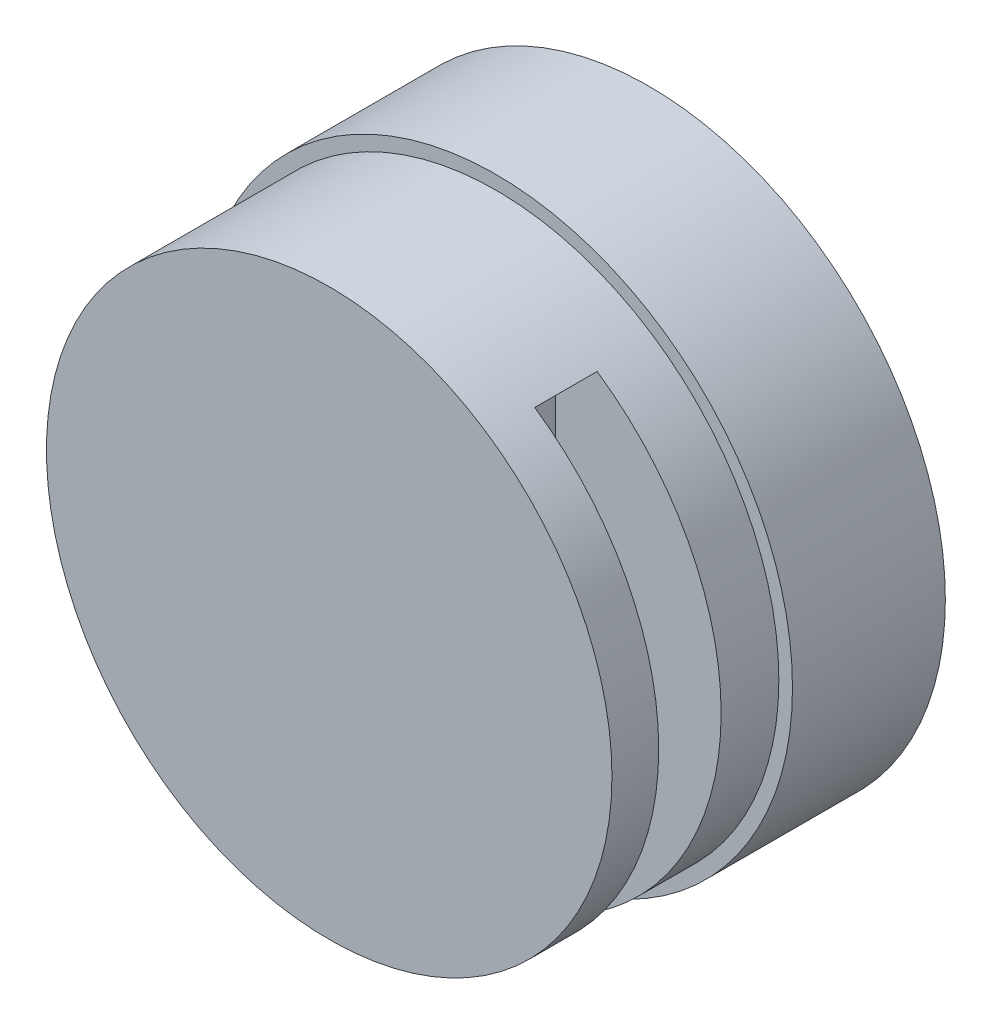
from build123d import *

# Parameters (mm, degrees)
SKETCH_1_R          = 38
EXTRUDE_1_DEPTH     = 19.6
SKETCH_2_R          = 36.25
EXTRUDE_2_DEPTH     = 21.4
SKETCH_3_R          = 1.5
CUT_EXTRUDE_1_DEPTH = 4
CUT_EXTRUDE_2_REACH = 55
CUT_EXTRUDE_START   = 15
SKETCH_5_W          = 8
SKETCH_5_H          = 60


with BuildPart() as part:
    # 草图1 → 凸台-拉伸1 (new body)
    with BuildSketch(Plane.XY):
        Circle(SKETCH_1_R)
    extrude(amount=EXTRUDE_1_DEPTH)

    # 草图2 → 凸台-拉伸2 (add)
    with BuildSketch(Plane.XY.offset(19.6)):
        Circle(SKETCH_2_R)
    extrude(amount=EXTRUDE_2_DEPTH)

    # 草图3 → 切除-拉伸1 (cut)
    with BuildSketch(Plane(origin=(0, 0, 0), x_dir=(-1, 0, 0), z_dir=(0, 0, -1))):
        with Locations((20.859650045, 20.859650045)):
            Circle(SKETCH_3_R)
        with Locations((20.859650045, -20.859650045)):
            Circle(SKETCH_3_R)
        with Locations((-20.859650045, -20.859650045)):
            Circle(SKETCH_3_R)
        with Locations((-20.859650045, 20.859650045)):
            Circle(SKETCH_3_R)
    extrude(amount=-CUT_EXTRUDE_1_DEPTH, mode=Mode.SUBTRACT)

    # 草图5 → 切除-拉伸2 (cut, up to next)
    with BuildSketch(Plane(origin=(0, 0, 0), x_dir=(0, 0, -1), z_dir=(1, 0, 0)).offset(CUT_EXTRUDE_START), mode=Mode.PRIVATE) as cut_extrude_2_sk1:
        with Locations((-31, 0)):
            Rectangle(SKETCH_5_W, SKETCH_5_H)
    cut_extrude_2_tool1 = extrude(cut_extrude_2_sk1.sketch, amount=CUT_EXTRUDE_2_REACH, mode=Mode.PRIVATE) & part.part
    add(cut_extrude_2_tool1.solids().sort_by_distance((15, 0, 31))[0], mode=Mode.SUBTRACT)


solid = part.part
